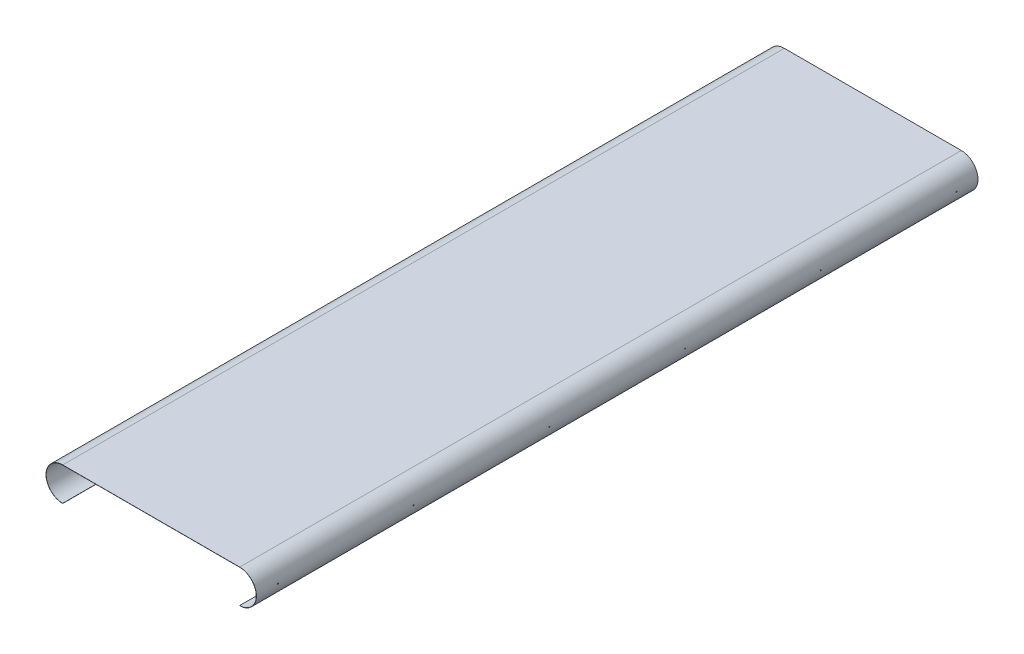
from build123d import *

# Parameters (mm, degrees)
SURFACE_EXTRUDE1_1_DEPTH = 2180
THICKEN1_T1              = 0.5
CUT_EXTRUDE1_START       = -2260.399186119
SKETCH2_R                = 1.5
CUT_EXTRUDE1_DEPTH       = 2892.399186119
LPATTERN1_COUNT          = 6
LPATTERN1_PITCH          = 410


with BuildPart() as body_1:
    # Surface-Extrude1: a surface, the sketch's curves swept straight by 2180 mm
    with BuildLine(Plane.XY, mode=Mode.PRIVATE) as surface_extrude1_1_path:
        ThreePointArc((0, -100), (-50, -50), (0, 0))
        Line((0, 0), (534.636251, 0))
        ThreePointArc((534.636251, 0), (584.636251, -50), (534.636251, -100))
    surface_extrude1_1 = Shell.extrude(surface_extrude1_1_path.wire(), (0 * SURFACE_EXTRUDE1_1_DEPTH, 0 * SURFACE_EXTRUDE1_1_DEPTH, 1 * SURFACE_EXTRUDE1_1_DEPTH))
    add(Solid.thicken(surface_extrude1_1, THICKEN1_T1))

    # Sketch2 → Cut-Extrude1 (cut)
    with BuildSketch(Plane(origin=(0, 0, 0), x_dir=(0, 0, -1), z_dir=(1, 0, 0)).offset(CUT_EXTRUDE1_START)):
        with Locations(Location((-2115, -50, 0), (0, 0, 180))):
            Circle(SKETCH2_R)
    cut_extrude1 = extrude(amount=CUT_EXTRUDE1_DEPTH, mode=Mode.SUBTRACT)

    # LPattern1: Cut-Extrude1 ×6
    with Locations(*[(0, 0, -i * LPATTERN1_PITCH) for i in range(1, LPATTERN1_COUNT)]):
        add(cut_extrude1, mode=Mode.SUBTRACT)


solid = body_1.part
